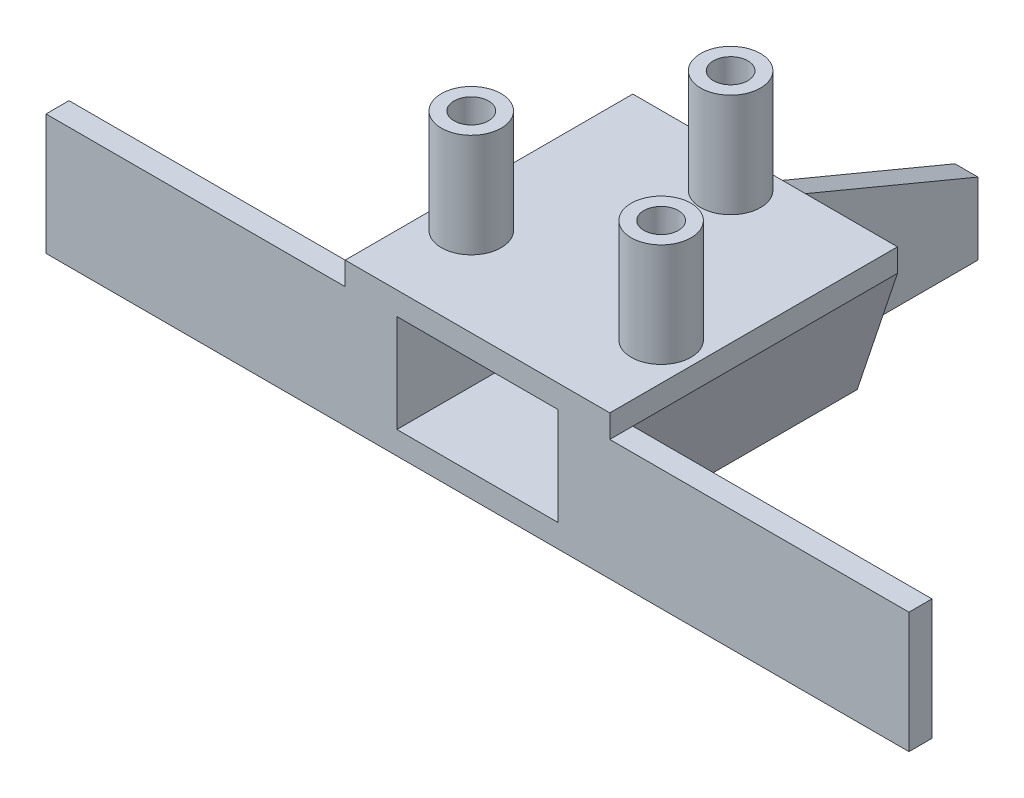
from build123d import *

# Parameters (mm, degrees)
SKETCH1_R             = 2.6
SKETCH1_R_2           = 1.5
BOSS_EXTRUDE1_DEPTH   = 9
BOSS_EXTRUDE1_2_DEPTH = 9
BOSS_EXTRUDE1_3_DEPTH = 9
SKETCH2_W             = 23
SKETCH2_H             = 25
BOSS_EXTRUDE2_DEPTH   = 12.5
CUT_EXTRUDE1_START    = -2
SKETCH3_W             = 14
SKETCH3_H             = 8.5
CUT_EXTRUDE1_DEPTH    = 24
BOSS_EXTRUDE3_START   = 11.5
SKETCH4_W             = 2
SKETCH4_H             = 10.5
BOSS_EXTRUDE3_DEPTH   = 26
BOSS_EXTRUDE4_START   = -11.5
SKETCH4_2_W           = 2
SKETCH4_2_H           = 10.5
BOSS_EXTRUDE4_DEPTH   = 26
SKETCH5_W             = 2
SKETCH5_H             = 12.5
BOSS_EXTRUDE5_DEPTH   = 15
CUT_EXTRUDE2_DEPTH    = 23
CUT_EXTRUDE3_DEPTH    = 2


with BuildPart() as part:
    # Sketch1 → Boss-Extrude1 (new body)
    with BuildSketch(Plane(origin=(0, 0, 0), x_dir=(1, 0, 0), z_dir=(0, 1, 0))):
        with Locations((-8.25, -14.289419162)):
            Circle(SKETCH1_R)
        with Locations((-8.25, -14.289419162)):
            Circle(SKETCH1_R_2, mode=Mode.SUBTRACT)
    extrude(amount=BOSS_EXTRUDE1_DEPTH)



with BuildPart() as body_2:
    # Sketch1 → Boss-Extrude1 2 (new body)
    with BuildSketch(Plane(origin=(0, 0, 0), x_dir=(1, 0, 0), z_dir=(0, 1, 0))):
        Circle(SKETCH1_R)
        Circle(SKETCH1_R_2, mode=Mode.SUBTRACT)
    extrude(amount=BOSS_EXTRUDE1_2_DEPTH)


with BuildPart() as body_3:
    # Sketch1 → Boss-Extrude1 3 (new body)
    with BuildSketch(Plane(origin=(0, 0, 0), x_dir=(1, 0, 0), z_dir=(0, 1, 0))):
        with Locations((8.25, -14.289419162)):
            Circle(SKETCH1_R)
        with Locations((8.25, -14.289419162)):
            Circle(SKETCH1_R_2, mode=Mode.SUBTRACT)
    extrude(amount=BOSS_EXTRUDE1_3_DEPTH)


with BuildPart() as part_1:
    add(part.part)

    add(body_2.part)  # Boss-Extrude2 merges body 2

    add(body_3.part)  # Boss-Extrude2 merges body 3
    # Sketch2 → Boss-Extrude2 (add)
    with BuildSketch(Plane(origin=(0, 0, 0), x_dir=(1, 0, 0), z_dir=(0, 1, 0))):
        with Locations((0, -9.5)):
            Rectangle(SKETCH2_W, SKETCH2_H)
    extrude(amount=-BOSS_EXTRUDE2_DEPTH)

    # Sketch3 → Cut-Extrude1 (cut, through all)
    with BuildSketch(Plane(origin=(0, 0, -3), x_dir=(-1, 0, 0), z_dir=(0, 0, -1)).offset(CUT_EXTRUDE1_START)):
        with Locations((0, -6.25)):
            Rectangle(SKETCH3_W, SKETCH3_H)
    extrude(amount=-CUT_EXTRUDE1_DEPTH, mode=Mode.SUBTRACT)

    # Sketch4 → Boss-Extrude3 (add)
    with BuildSketch(Plane.ZY.offset(BOSS_EXTRUDE3_START)):
        with Locations((21, -7.25)):
            Rectangle(SKETCH4_W, SKETCH4_H)
    extrude(amount=BOSS_EXTRUDE3_DEPTH)

    # Sketch4_2 → Boss-Extrude4 (add)
    with BuildSketch(Plane.ZY.offset(BOSS_EXTRUDE4_START)):
        with Locations((21, -7.25)):
            Rectangle(SKETCH4_2_W, SKETCH4_2_H)
    extrude(amount=-BOSS_EXTRUDE4_DEPTH)

    # Sketch5 → Boss-Extrude5 (add)
    with BuildSketch(Plane(origin=(0, 0, -3), x_dir=(-1, 0, 0), z_dir=(0, 0, -1))):
        with Locations((-2.5, -6.25)):
            Rectangle(SKETCH5_W, SKETCH5_H)
    extrude(amount=BOSS_EXTRUDE5_DEPTH)

    # Sketch6 → Cut-Extrude2 (cut)
    with BuildSketch(Plane.XY.offset(-3)):
        Polygon((-11.5, -2), (-8, -12.5), (-11.5, -12.5), align=None)
        Polygon((11.5, -2), (11.5, -12.5), (8, -12.5), align=None)
    extrude(amount=CUT_EXTRUDE2_DEPTH, mode=Mode.SUBTRACT)

    # Sketch7 → Cut-Extrude3 (cut)
    with BuildSketch(Plane.ZY.offset(-1.5)):
        Polygon((-18, 0), (-18, -6.25), (-3, 0), align=None)
    extrude(amount=-CUT_EXTRUDE3_DEPTH, mode=Mode.SUBTRACT)


solid = part_1.part
